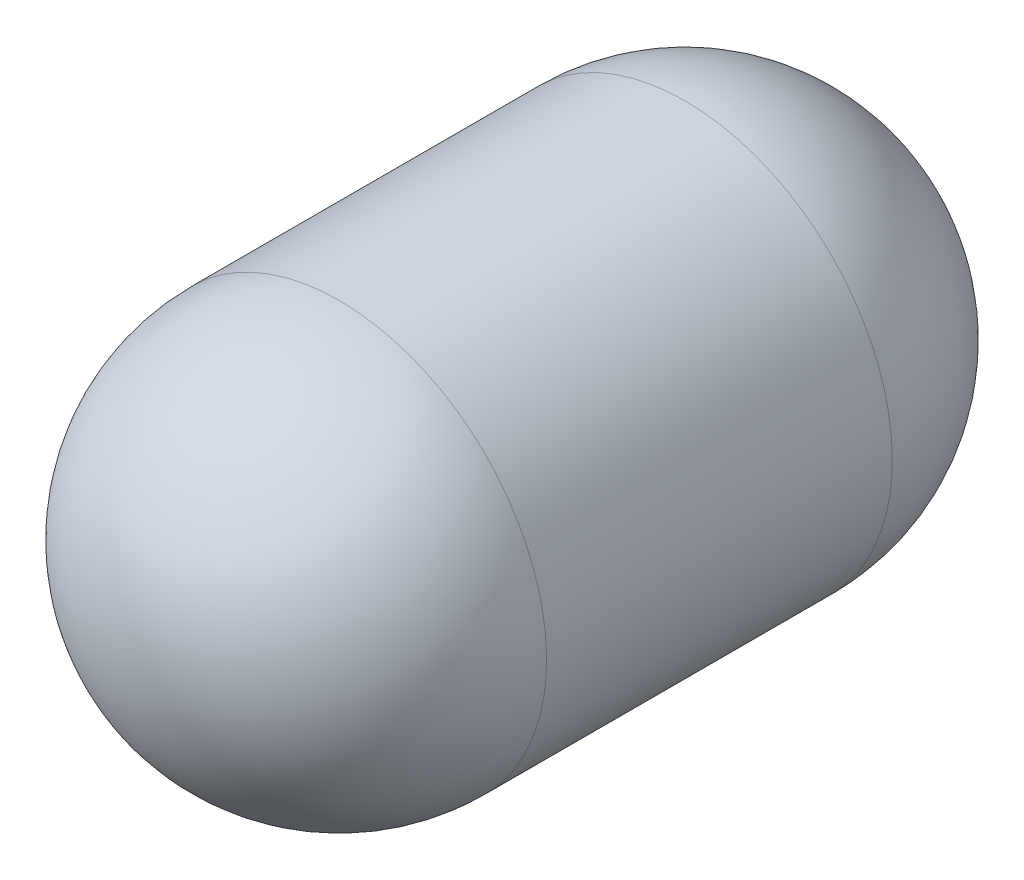
from build123d import *


with BuildPart() as part:
    # Tank Arc → Air Tank (revolve)
    with BuildSketch(Plane(origin=(0, 0, 0), x_dir=(0, 0, -1), z_dir=(1, 0, 0))):
        with BuildLine():
            Line((-63.5, 76.2), (63.5, 76.2))
            ThreePointArc((63.5, 76.2), (117.381536726, 53.881536726), (139.7, 0))
            Line((139.7, 0), (-139.7, 0))
            ThreePointArc((-139.7, 0), (-117.381536726, 53.881536726), (-63.5, 76.2))
        make_face()
    revolve(axis=Axis((0, 0, -139.7), (0, 0, 1)))


solid = part.part
